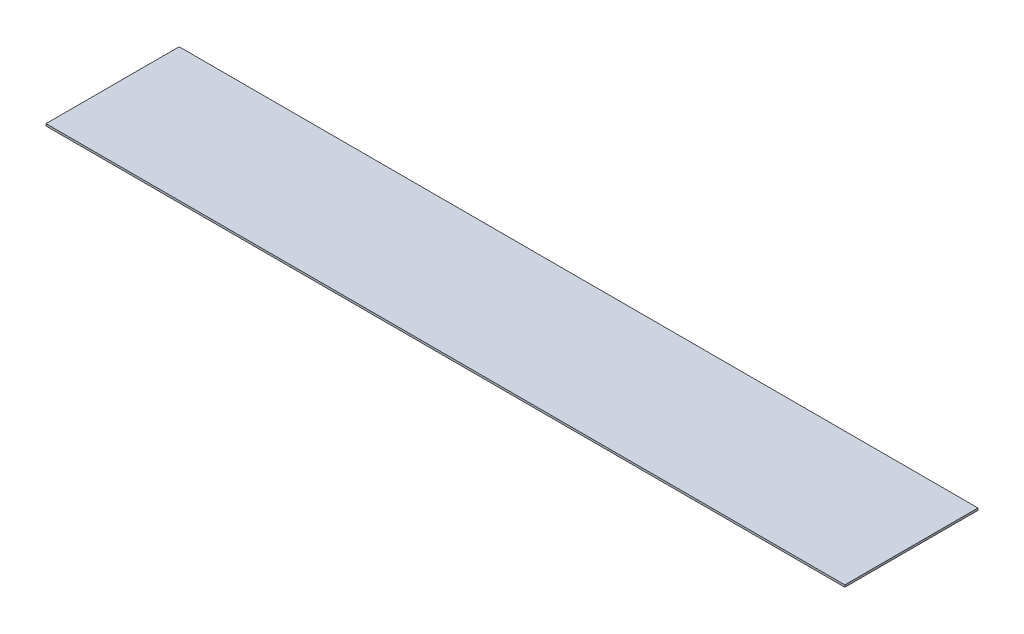
from build123d import *

# Parameters (mm, degrees)
SKETCH1_W           = 609.6
SKETCH1_H           = 101.6
BOSS_EXTRUDE1_DEPTH = 1.5875


with BuildPart() as part:
    # Sketch1 → Boss-Extrude1 (new body)
    with BuildSketch(Plane.XZ.offset(80.26236602)):
        with Locations((304.8, 50.8)):
            Rectangle(SKETCH1_W, SKETCH1_H)
    extrude(amount=BOSS_EXTRUDE1_DEPTH)


solid = part.part
